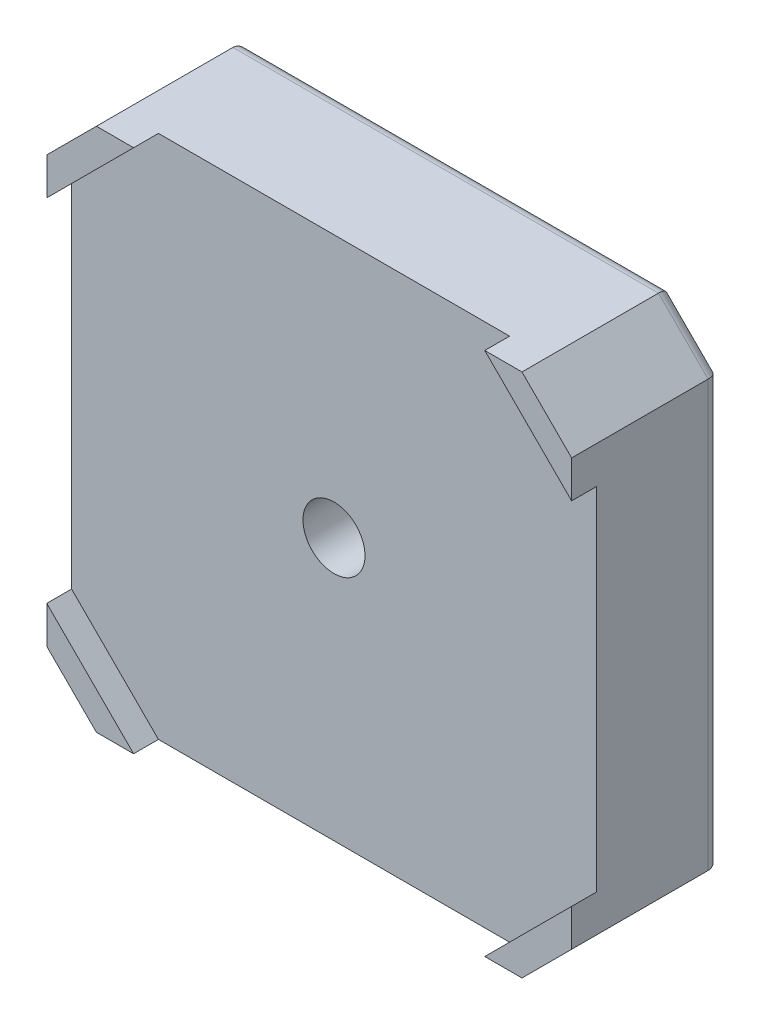
from build123d import *

# Parameters (mm, degrees)
BOSS_EXTRUDE1_DEPTH = 24
CUT_EXTRUDE1_DEPTH  = 4
SKETCH3_R           = 22
BOSS_EXTRUDE2_DEPTH = 4
SKETCH4_R           = 11
CUT_EXTRUDE3_DEPTH  = 14
SKETCH5_R           = 5
CUT_EXTRUDE4_DEPTH  = 15
FILLET1_R           = 2
FILLET2_R           = 1
SKETCH6_R           = 3
CUT_EXTRUDE5_DEPTH  = 6
FILLET3_R           = 1


with BuildPart() as part:
    # Sketch1 → Boss-Extrude1 (new body)
    with BuildSketch(Plane.XY):
        Polygon((-42.3, 34.3), (-34.3, 42.3), (34.3, 42.3), (42.3, 34.3), (42.3, -34.3), (34.3, -42.3), (-34.3, -42.3), (-42.3, -34.3), align=None)
    extrude(amount=BOSS_EXTRUDE1_DEPTH)

    # Sketch2 → Cut-Extrude1 (cut)
    with BuildSketch(Plane.XY.offset(24)):
        Polygon((-42.3, 28.3), (-28.3, 42.3), (28.3, 42.3), (42.3, 28.3), (42.3, -28.3), (28.3, -42.3), (-28.3, -42.3), (-42.3, -28.3), align=None)
    extrude(amount=-CUT_EXTRUDE1_DEPTH, mode=Mode.SUBTRACT)

    # Sketch3 → Boss-Extrude2 (add)
    with BuildSketch(Plane(origin=(0, 0, 0), x_dir=(-1, 0, 0), z_dir=(0, 0, -1))):
        Circle(SKETCH3_R)
    extrude(amount=BOSS_EXTRUDE2_DEPTH)

    # Sketch4 → Cut-Extrude3 (cut)
    with BuildSketch(Plane(origin=(0, 0, -4), x_dir=(-1, 0, 0), z_dir=(0, 0, -1))):
        Circle(SKETCH4_R)
    extrude(amount=-CUT_EXTRUDE3_DEPTH, mode=Mode.SUBTRACT)

    # Sketch5 → Cut-Extrude4 (cut, through all)
    with BuildSketch(Plane(origin=(0, 0, 10), x_dir=(-1, 0, 0), z_dir=(0, 0, -1))):
        Circle(SKETCH5_R)
    extrude(amount=-CUT_EXTRUDE4_DEPTH, mode=Mode.SUBTRACT)

    # Fillet1
    fillet1_edges = [part.edges().sort_by_distance(p)[0] for p in [
        (-38.3, -38.3, 0),
        (-42.3, 0, 0),
        (-38.3, 38.3, 0),
        (0, 42.3, 0),
        (38.3, 38.3, 0),
        (42.3, 0, 0),
        (38.3, -38.3, 0),
        (0, -42.3, 0),
    ]]
    fillet(fillet1_edges, radius=FILLET1_R)

    # Fillet2
    fillet2_edges = [part.edges().sort_by_distance(p)[0] for p in [
        (22, 0, -4),
        (11, 0, 10),
        (11, 0, -4),
    ]]
    fillet(fillet2_edges, radius=FILLET2_R)

    # Sketch6 → Cut-Extrude5 (cut)
    with BuildSketch(Plane(origin=(0, 0, 0), x_dir=(-1, 0, 0), z_dir=(0, 0, -1))):
        with Locations((-31, 31)):
            Circle(SKETCH6_R)
        with Locations((31, 31)):
            Circle(SKETCH6_R)
        with Locations((31, -31)):
            Circle(SKETCH6_R)
        with Locations((-31, -31)):
            Circle(SKETCH6_R)
    extrude(amount=-CUT_EXTRUDE5_DEPTH, mode=Mode.SUBTRACT)

    # Fillet3
    fillet3_edges = [part.edges().sort_by_distance(p)[0] for p in [
        (34, -31, 0),
        (-28, -31, 0),
        (-28, 31, 0),
        (34, 31, 0),
    ]]
    fillet(fillet3_edges, radius=FILLET3_R)


solid = part.part
